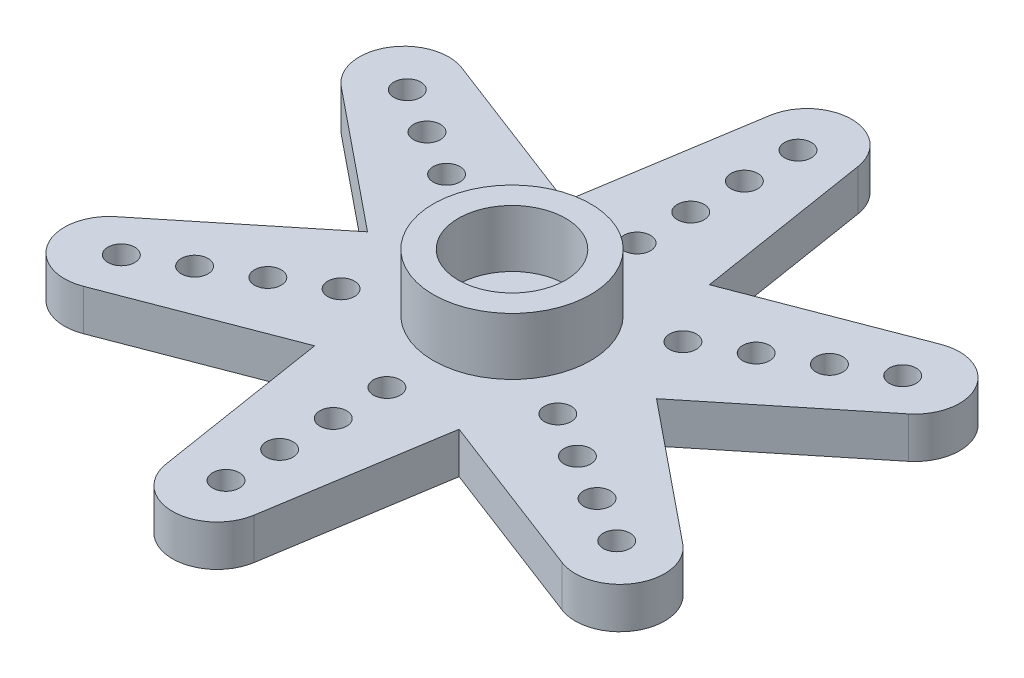
from build123d import *

# Parameters (mm, degrees)
SKETCH1_R           = 6.1
SKETCH1_R_2         = 1.5
BOSS_EXTRUDE1_DEPTH = 2.3
SKETCH2_R           = 4.4
SKETCH2_R_2         = 3
BOSS_EXTRUDE2_DEPTH = 3.2
SKETCH3_R           = 0.75
BOSS_EXTRUDE3_DEPTH = 2.3
CIRPATTERN1_COUNT   = 6


with BuildPart() as part:
    # Sketch1 → Boss-Extrude1 (new body)
    with BuildSketch(Plane(origin=(0, 0, 0), x_dir=(1, 0, 0), z_dir=(0, 1, 0))):
        Circle(SKETCH1_R)
        Circle(SKETCH1_R_2, mode=Mode.SUBTRACT)
    extrude(amount=BOSS_EXTRUDE1_DEPTH)

    # Sketch2 → Boss-Extrude2 (add)
    with BuildSketch(Plane(origin=(0, 2.3, 0), x_dir=(1, 0, 0), z_dir=(0, 1, 0))):
        Circle(SKETCH2_R)
        Circle(SKETCH2_R_2, mode=Mode.SUBTRACT)
    extrude(amount=BOSS_EXTRUDE2_DEPTH)

    # Sketch3 → Boss-Extrude3 (add)
    with BuildSketch(Plane.XZ):
        with BuildLine():
            Line((-4.5, -4.118252056), (-2.468988638, -16.892549493))
            ThreePointArc((-2.468988638, -16.892549493), (0, -19), (2.468988638, -16.892549493))
            Line((2.468988638, -16.892549493), (4.5, -4.118252056))
            ThreePointArc((4.5, -4.118252056), (0, -6.1), (-4.5, -4.118252056))
        make_face()
        with Locations((0, -16)):
            Circle(SKETCH3_R, mode=Mode.SUBTRACT)
        with Locations((0, -13)):
            Circle(SKETCH3_R, mode=Mode.SUBTRACT)
        with Locations((0, -10)):
            Circle(SKETCH3_R, mode=Mode.SUBTRACT)
        with Locations((0, -7)):
            Circle(SKETCH3_R, mode=Mode.SUBTRACT)
    boss_extrude3 = extrude(amount=-BOSS_EXTRUDE3_DEPTH)

    # CirPattern1: Boss-Extrude3 ×6 about axis
    cirpattern1_axis = Axis((0, 0, 0), (0, 1, 0))
    for i in range(1, CIRPATTERN1_COUNT):
        add(boss_extrude3.rotate(cirpattern1_axis, i * 360 / CIRPATTERN1_COUNT))


solid = part.part
